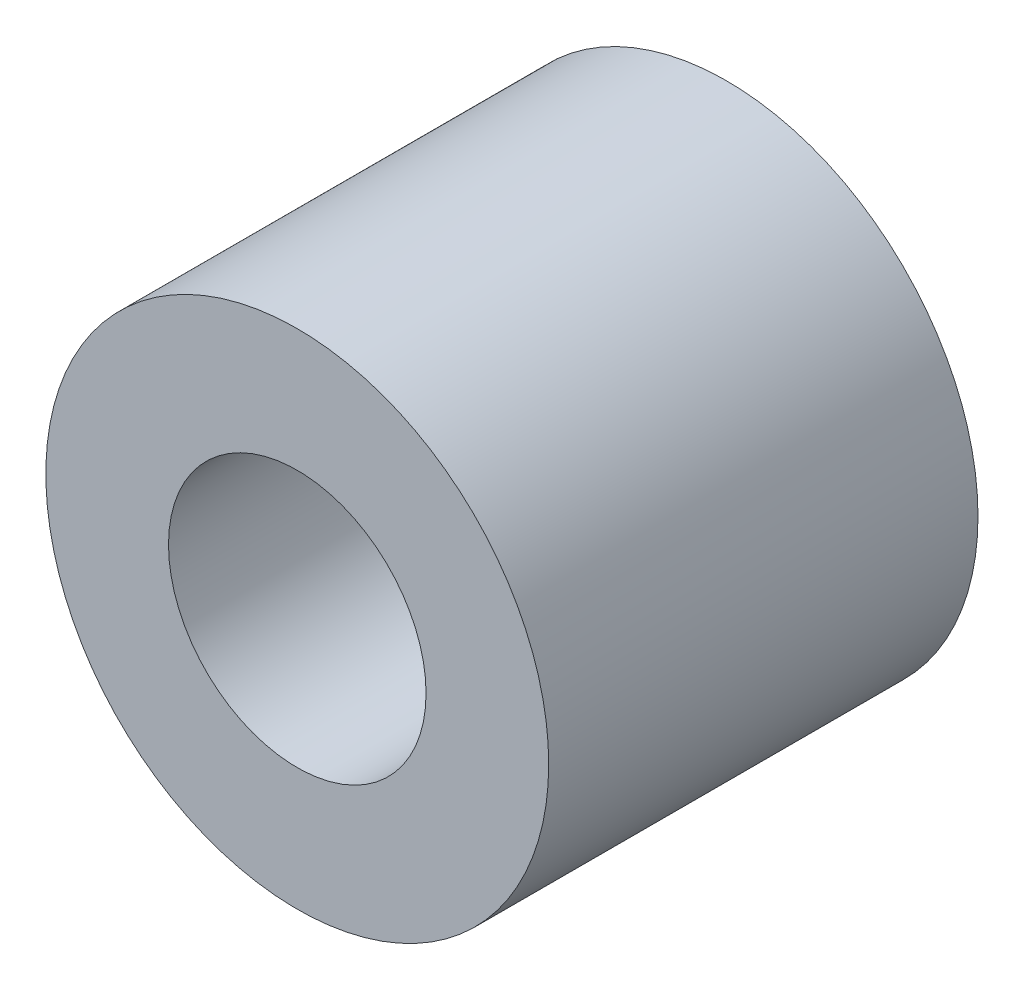
from build123d import *

# Parameters (mm, degrees)
SKETCH2_R           = 6.15
SKETCH2_R_2         = 3.15
BOSS_EXTRUDE1_DEPTH = 10.5


with BuildPart() as part:
    # Sketch2 → Boss-Extrude1 (new body)
    with BuildSketch(Plane.XY):
        Circle(SKETCH2_R)
        Circle(SKETCH2_R_2, mode=Mode.SUBTRACT)
    extrude(amount=BOSS_EXTRUDE1_DEPTH)


solid = part.part
